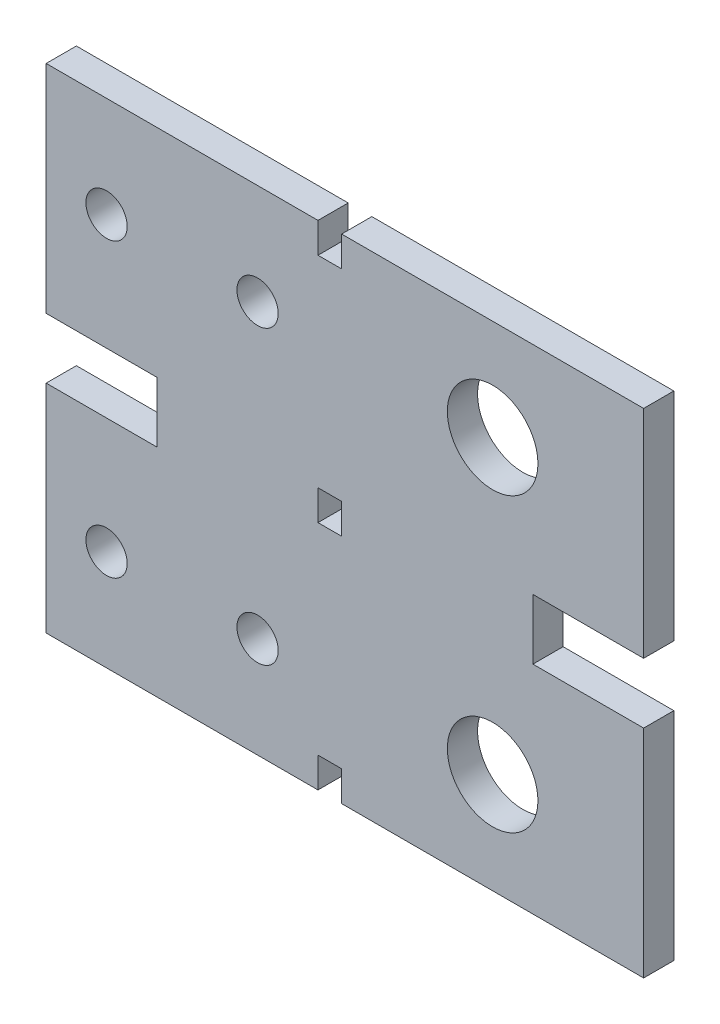
from build123d import *

# Parameters (mm, degrees)
SKETCH2_W           = 27
SKETCH2_H           = 49
SKETCH2_R           = 2.05
BOSS_EXTRUDE1_DEPTH = 3
SKETCH8_R           = 4.5
BOSS_EXTRUDE3_DEPTH = 3
SKETCH9_W           = 11
SKETCH9_H           = 6
CUT_EXTRUDE4_DEPTH  = 4


with BuildPart() as part:
    # Sketch2 → Boss-Extrude1 (new body)
    with BuildSketch(Plane.XY):
        with Locations((13.5, 24.5)):
            Rectangle(SKETCH2_W, SKETCH2_H)
        with Locations((6, 39)):
            Circle(SKETCH2_R, mode=Mode.SUBTRACT)
        with Locations((21, 39)):
            Circle(SKETCH2_R, mode=Mode.SUBTRACT)
        with Locations((6, 10)):
            Circle(SKETCH2_R, mode=Mode.SUBTRACT)
        with Locations((21, 10)):
            Circle(SKETCH2_R, mode=Mode.SUBTRACT)
    extrude(amount=BOSS_EXTRUDE1_DEPTH)

    # Sketch8 → Boss-Extrude3 (add)
    with BuildSketch(Plane.XY.offset(3)):
        Polygon((29.35, 0), (59.35, 0), (59.35, 49), (29.35, 49), (29.35, 46), (27, 46), (27, 26), (29.35, 26), (29.35, 23), (27, 23), (27, 3), (29.35, 3), align=None)
        with Locations((44.35, 39)):
            Circle(SKETCH8_R, mode=Mode.SUBTRACT)
        with Locations((44.35, 10)):
            Circle(SKETCH8_R, mode=Mode.SUBTRACT)
    extrude(amount=-BOSS_EXTRUDE3_DEPTH)

    # Sketch9 → Cut-Extrude4 (cut, through all)
    with BuildSketch(Plane.XY.offset(3)):
        with Locations((5.5, 24.5)):
            Rectangle(SKETCH9_W, SKETCH9_H)
        with Locations((53.85, 24.5)):
            Rectangle(SKETCH9_W, SKETCH9_H)
    extrude(amount=-CUT_EXTRUDE4_DEPTH, mode=Mode.SUBTRACT)


solid = part.part
